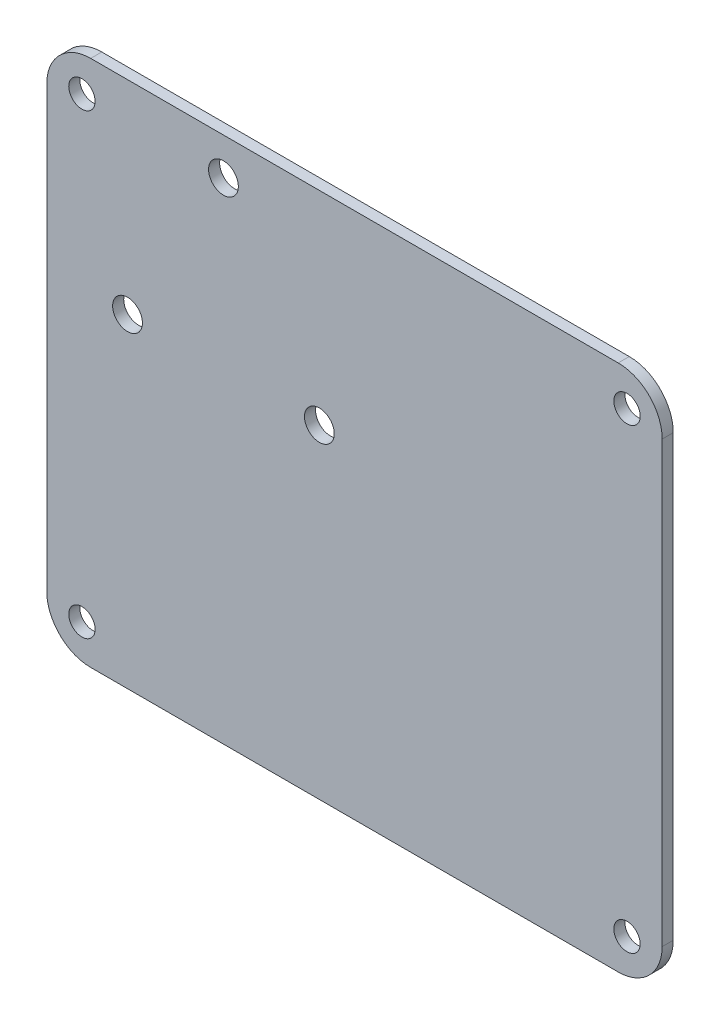
from build123d import *

# Parameters (mm, degrees)
SKETCH1_W           = 88.9
SKETCH1_H           = 76.2
BOSS_EXTRUDE1_DEPTH = 1.6
SKETCH2_R           = 2.15
CUT_EXTRUDE1_DEPTH  = 2.6
SKETCH4_R           = 1.905
CUT_EXTRUDE2_DEPTH  = 2.6
FILLET1_R           = 6.35


with BuildPart() as part:
    # Sketch1 → Boss-Extrude1 (new body)
    with BuildSketch(Plane.XY):
        with Locations((28.959521177, 30.063142475)):
            Rectangle(SKETCH1_W, SKETCH1_H)
    extrude(amount=BOSS_EXTRUDE1_DEPTH)

    # Sketch2 → Cut-Extrude1 (cut, through all)
    with BuildSketch(Plane(origin=(0, 0, 0), x_dir=(-1, 0, 0), z_dir=(0, 0, -1))):
        with Locations((-23.890706089, 38.789996981)):
            Circle(SKETCH2_R)
        with Locations((3.822106833, 38.789996981)):
            Circle(SKETCH2_R)
        with Locations((-10.034299628, 62.789996981)):
            Circle(SKETCH2_R)
    extrude(amount=-CUT_EXTRUDE1_DEPTH, mode=Mode.SUBTRACT)

    # Sketch4 → Cut-Extrude2 (cut, through all)
    with BuildSketch(Plane(origin=(0, 0, 0), x_dir=(-1, 0, 0), z_dir=(0, 0, -1))):
        with Locations((10.410478823, 63.083142475)):
            Circle(SKETCH4_R)
        with Locations((-68.329521177, 63.083142475)):
            Circle(SKETCH4_R)
        with Locations((-68.329521177, -2.956857525)):
            Circle(SKETCH4_R)
        with Locations((10.410478823, -2.956857525)):
            Circle(SKETCH4_R)
    extrude(amount=-CUT_EXTRUDE2_DEPTH, mode=Mode.SUBTRACT)

    # Fillet1
    fillet1_edges = [part.edges().sort_by_distance(p)[0] for p in [
        (-15.490478823, 68.163142475, 0.8),
        (73.409521177, 68.163142475, 0.8),
        (73.409521177, -8.036857525, 0.8),
        (-15.490478823, -8.036857525, 0.8),
    ]]
    fillet(fillet1_edges, radius=FILLET1_R)


solid = part.part
